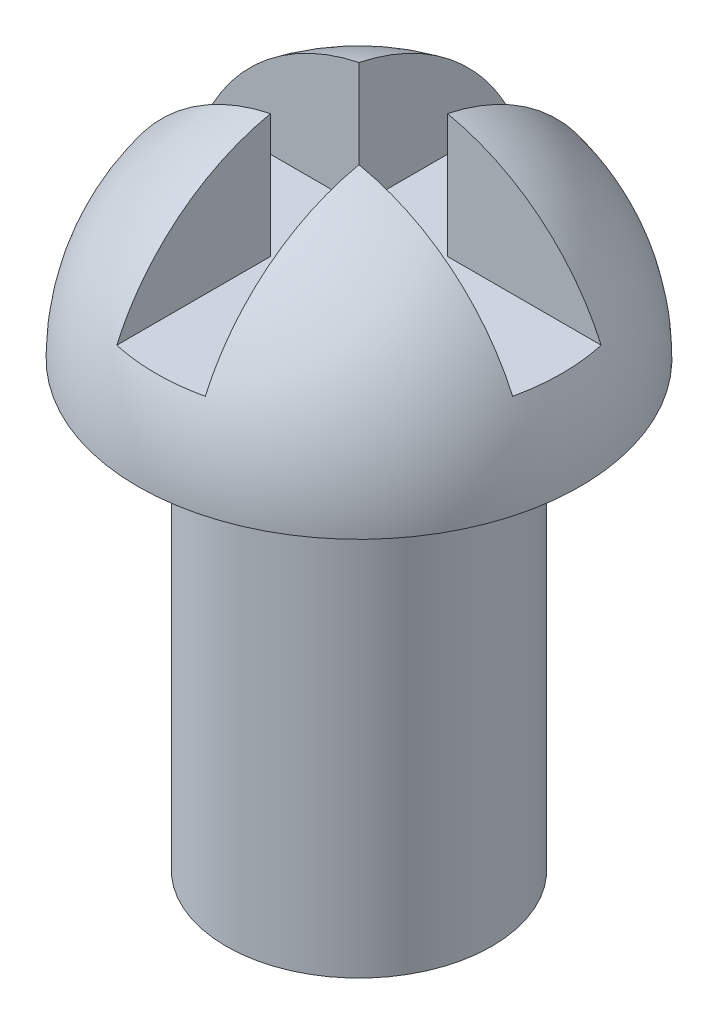
from build123d import *

# Parameters (mm, degrees)
SKETCH1_R           = 1.5
BOSS_EXTRUDE1_DEPTH = 5
REVOLVE1_ANGLE      = 180
CUT_EXTRUDE1_DEPTH  = 2


with BuildPart() as part:
    # Sketch1 → Boss-Extrude1 (new body)
    with BuildSketch(Plane(origin=(0, 0, 0), x_dir=(1, 0, 0), z_dir=(0, 1, 0))):
        Circle(SKETCH1_R)
    extrude(amount=BOSS_EXTRUDE1_DEPTH)

    # Sketch2 → Revolve1 (revolve)
    with BuildSketch(Plane(origin=(0, 5, 0), x_dir=(1, 0, 0), z_dir=(0, 1, 0))):
        with BuildLine():
            Line((0, 2.5), (0, -2.5))
            ThreePointArc((0, -2.5), (2.5, 0), (0, 2.5))
        make_face()
    revolve(axis=Axis((0, 5, -2.5), (0, 0, 1)), revolution_arc=REVOLVE1_ANGLE)

    # Sketch3 → Cut-Extrude1 (cut)
    with BuildSketch(Plane(origin=(0, 8, 0), x_dir=(1, 0, 0), z_dir=(0, 1, 0))):
        Polygon((-0.5, -0.5), (-0.5, -3.128554583), (0.5, -3.128554583), (0.5, -0.5), (2.950746735, -0.5), (2.950746735, 0.5), (0.5, 0.5), (0.5, 2.871445417), (-0.5, 2.871445417), (-0.5, 0.5), (-3.049253265, 0.5), (-3.049253265, -0.5), align=None)
    extrude(amount=-CUT_EXTRUDE1_DEPTH, mode=Mode.SUBTRACT)


solid = part.part
